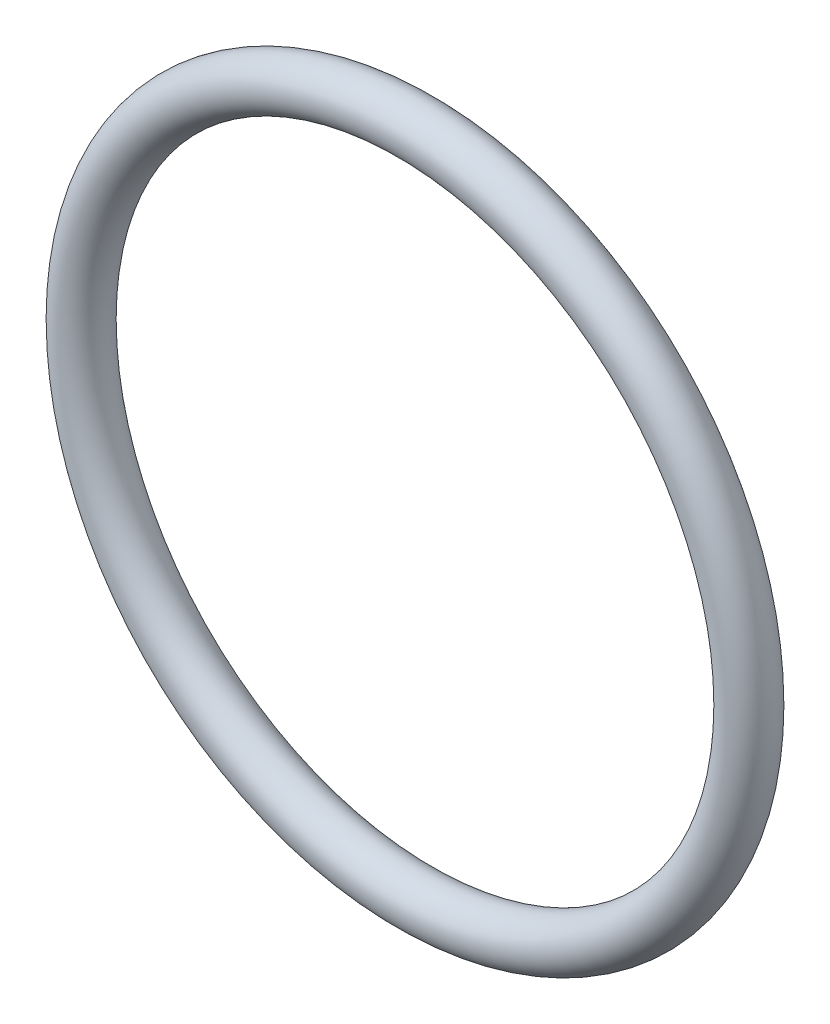
from build123d import *

# Parameters (mm, degrees)
SKETCH1_R = 1.7653


with BuildPart() as part:
    # Sketch1 → Revolve1 (revolve)
    with BuildSketch(Plane(origin=(0, 0, 0), x_dir=(0, -1, 0), z_dir=(1, 0, 0))):
        with Locations((23.7871, 0)):
            Circle(SKETCH1_R)
    revolve(axis=Axis((0, 0, 1.7653), (0, 0, -1)))


solid = part.part
